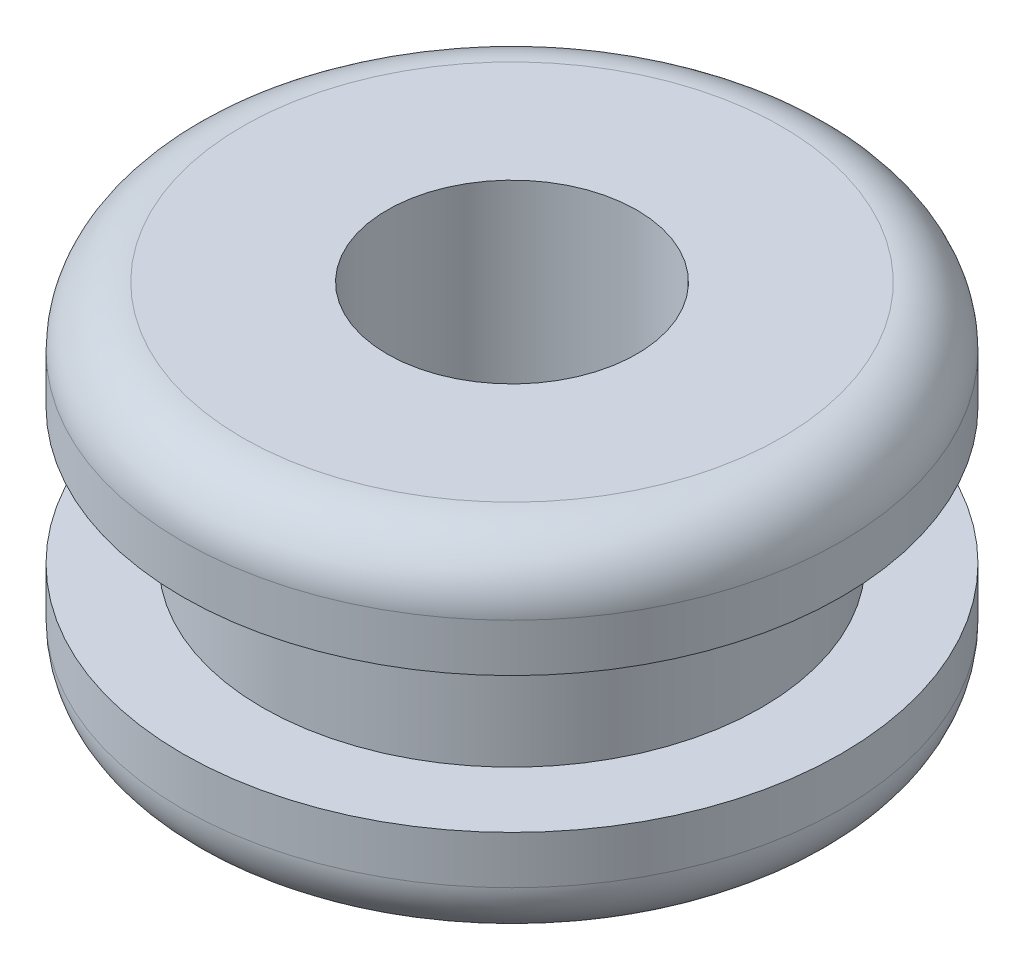
from build123d import *

# Parameters (mm, degrees)
SKETCH1_R           = 4.191
BOSS_EXTRUDE1_DEPTH = 1.3716
SKETCH2_R           = 3.175
BOSS_EXTRUDE2_DEPTH = 1.7272
SKETCH3_R           = 4.191
BOSS_EXTRUDE3_DEPTH = 1.3716
SKETCH4_R           = 1.5875
CUT_EXTRUDE1_DEPTH  = 5.4704
FILLET1_R           = 0.762


with BuildPart() as part:
    # Sketch1 → Boss-Extrude1 (new body)
    with BuildSketch(Plane(origin=(0, 0, 0), x_dir=(1, 0, 0), z_dir=(0, 1, 0))):
        Circle(SKETCH1_R)
    extrude(amount=BOSS_EXTRUDE1_DEPTH)

    # Sketch2 → Boss-Extrude2 (add)
    with BuildSketch(Plane(origin=(0, 1.3716, 0), x_dir=(1, 0, 0), z_dir=(0, 1, 0))):
        Circle(SKETCH2_R)
    extrude(amount=BOSS_EXTRUDE2_DEPTH)

    # Sketch3 → Boss-Extrude3 (add)
    with BuildSketch(Plane(origin=(0, 3.0988, 0), x_dir=(1, 0, 0), z_dir=(0, 1, 0))):
        Circle(SKETCH3_R)
    extrude(amount=BOSS_EXTRUDE3_DEPTH)

    # Sketch4 → Cut-Extrude1 (cut, through all)
    with BuildSketch(Plane(origin=(0, 4.4704, 0), x_dir=(1, 0, 0), z_dir=(0, 1, 0))):
        Circle(SKETCH4_R)
    extrude(amount=-CUT_EXTRUDE1_DEPTH, mode=Mode.SUBTRACT)

    # Fillet1
    fillet1_edges = [part.edges().sort_by_distance(p)[0] for p in [
        (-4.191, 4.4704, 0),
        (-4.191, 0, 0),
    ]]
    fillet(fillet1_edges, radius=FILLET1_R)


solid = part.part
